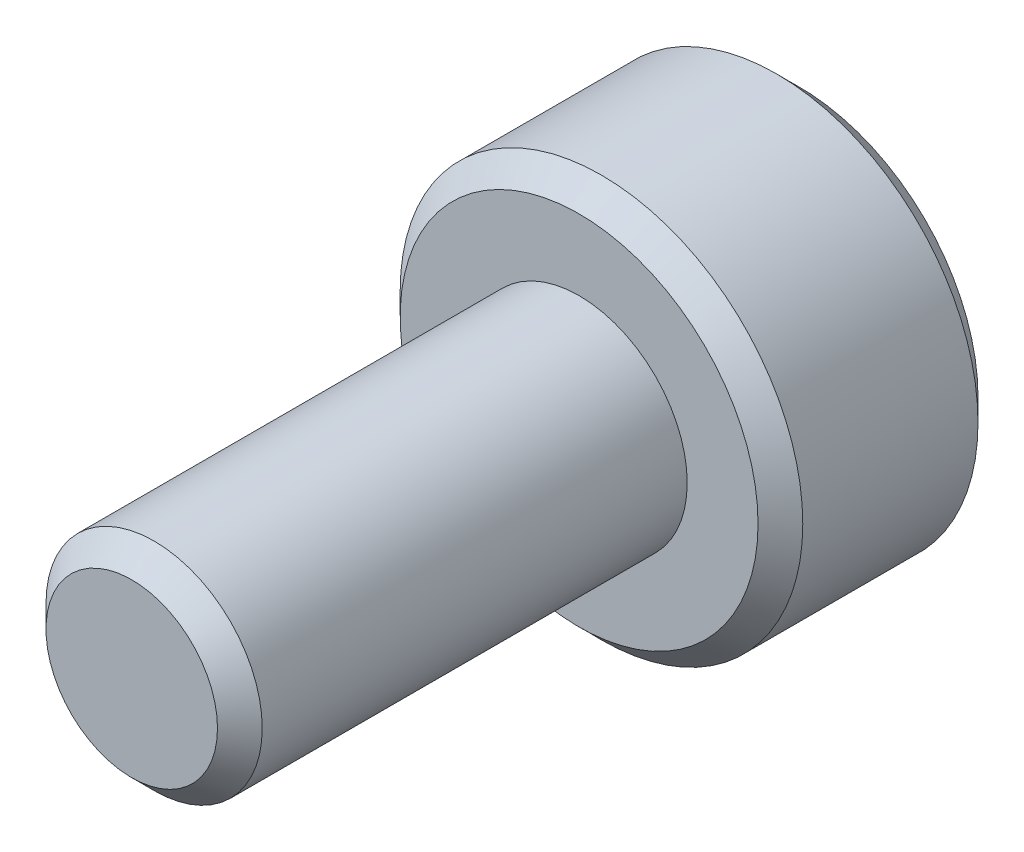
from build123d import *

# Parameters (mm, degrees)
SKIZZE1_R                       = 2.7
AUFSATZ_LINEAR_AUSTRAGEN1_DEPTH = 2.95
SKIZZE2_R                       = 1.45
AUFSATZ_LINEAR_AUSTRAGEN2_DEPTH = 6
FASE1_SIZE                      = 0.3
SCHNITT_LINEAR_AUSTRAGEN1_DEPTH = 2.5


with BuildPart() as part:
    # Skizze1 → Aufsatz-Linear austragen1 (new body)
    with BuildSketch(Plane.XY):
        Circle(SKIZZE1_R)
    extrude(amount=AUFSATZ_LINEAR_AUSTRAGEN1_DEPTH)

    # Skizze2 → Aufsatz-Linear austragen2 (add)
    with BuildSketch(Plane.XY.offset(2.95)):
        Circle(SKIZZE2_R)
    extrude(amount=AUFSATZ_LINEAR_AUSTRAGEN2_DEPTH)

    # Fase1
    fase1_edges = [part.edges().sort_by_distance(p)[0] for p in [
        (-2.7, 0, 0),
        (-2.7, 0, 2.95),
        (-1.45, 0, 8.95),
    ]]
    chamfer(fase1_edges, length=FASE1_SIZE)

    # Skizze3 → Schnitt-Linear austragen1 (cut)
    with BuildSketch(Plane(origin=(0, 0, 0), x_dir=(-1, 0, 0), z_dir=(0, 0, -1))):
        Polygon((1.25, 0.721687836), (0, 1.443375673), (-1.25, 0.721687836), (-1.25, -0.721687836), (0, -1.443375673), (1.25, -0.721687836), align=None)
    extrude(amount=-SCHNITT_LINEAR_AUSTRAGEN1_DEPTH, mode=Mode.SUBTRACT)


solid = part.part
